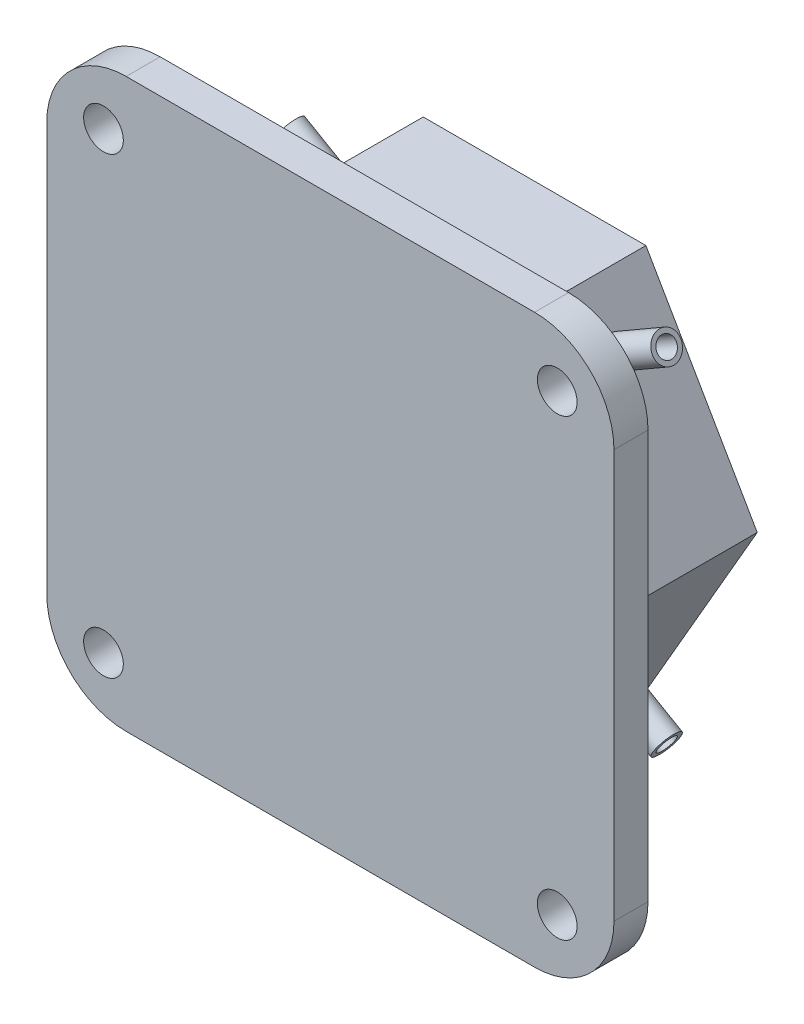
from build123d import *

# Parameters (mm, degrees)
SKETCH_1_R           = 1.75
EXTRUDE_3_DEPTH      = 3
EXTRUDE_4_DEPTH      = 15
SKETCH_3_R           = 1
CUT_EXTRUDE_5_DEPTH  = 7.5
SKETCH_8_R           = 0.85
CUT_EXTRUDE_8_DEPTH  = 9
SKETCH_10_R          = 0.85
CUT_EXTRUDE_9_DEPTH  = 9
SKETCH_11_R          = 0.85
CUT_EXTRUDE_10_DEPTH = 9
SKETCH_12_R          = 0.85
CUT_EXTRUDE_11_DEPTH = 9
SKETCH_13_R          = 1.25
SKETCH_13_R_2        = 0.85
EXTRUDE_5_DEPTH      = 5
SKETCH_14_R          = 1.25
SKETCH_14_R_2        = 0.85
EXTRUDE_6_DEPTH      = 5
SKETCH_15_R          = 1.25
SKETCH_15_R_2        = 0.85
EXTRUDE_7_DEPTH      = 5
SKETCH_16_R          = 1.25
SKETCH_16_R_2        = 0.85
EXTRUDE_8_DEPTH      = 5
SKETCH_17_R          = 1.25
SKETCH_17_R_2        = 1
EXTRUDE_9_DEPTH      = 5


with BuildPart() as part:
    # 草图1 → 凸台-拉伸3 (new body)
    with BuildSketch(Plane.XY):
        with BuildLine():
            Line((-18, -25), (18, -25))
            ThreePointArc((18, -25), (22.949747468, -22.949747468), (25, -18))
            Line((25, -18), (25, 18))
            ThreePointArc((25, 18), (22.949747468, 22.949747468), (18, 25))
            Line((18, 25), (-18, 25))
            ThreePointArc((-18, 25), (-22.949747468, 22.949747468), (-25, 18))
            Line((-25, 18), (-25, -18))
            ThreePointArc((-25, -18), (-22.949747468, -22.949747468), (-18, -25))
        make_face()
        with Locations((20, 20)):
            Circle(SKETCH_1_R, mode=Mode.SUBTRACT)
        with Locations((-20, 20)):
            Circle(SKETCH_1_R, mode=Mode.SUBTRACT)
        with Locations((-20, -20)):
            Circle(SKETCH_1_R, mode=Mode.SUBTRACT)
        with Locations((20, -20)):
            Circle(SKETCH_1_R, mode=Mode.SUBTRACT)
    extrude(amount=EXTRUDE_3_DEPTH)

    # 草图2 → 凸台-拉伸4 (add)
    with BuildSketch(Plane(origin=(0, 0, 0), x_dir=(-1, 0, 0), z_dir=(0, 0, -1))):
        Polygon((9.814954576, -17), (19.629909152, 0), (9.814954576, 17), (-9.814954576, 17), (-19.629909152, 0), (-9.814954576, -17), align=None)
    extrude(amount=EXTRUDE_4_DEPTH)

    # 草图3 → 切除-拉伸5 (cut)
    with BuildSketch(Plane(origin=(0, 0, -15), x_dir=(-1, 0, 0), z_dir=(0, 0, -1))):
        with Locations((-4.815101245, 8.34)):
            Circle(SKETCH_3_R)
        with Locations((4.815101245, 8.34)):
            Circle(SKETCH_3_R)
        with Locations((4.815101245, -8.34)):
            Circle(SKETCH_3_R)
        with Locations((-4.815101245, -8.34)):
            Circle(SKETCH_3_R)
    extrude(amount=-CUT_EXTRUDE_5_DEPTH, mode=Mode.SUBTRACT)

    # 草图8 → 切除-拉伸8 (cut)
    with BuildSketch(Plane(origin=(14.722431864, 8.5, 0), x_dir=(0, 0, -1), z_dir=(0.866025404, 0.5, 0))):
        with Locations((10, 4.814954576)):
            Circle(SKETCH_8_R)
    extrude(amount=-CUT_EXTRUDE_8_DEPTH, mode=Mode.SUBTRACT)

    # 草图10 → 切除-拉伸9 (cut)
    with BuildSketch(Plane(origin=(-14.722431864, 8.5, 0), x_dir=(0, 0, 1), z_dir=(-0.866025404, 0.5, 0))):
        with Locations((-10, 4.814954576)):
            Circle(SKETCH_10_R)
    extrude(amount=-CUT_EXTRUDE_9_DEPTH, mode=Mode.SUBTRACT)

    # 草图11 → 切除-拉伸10 (cut)
    with BuildSketch(Plane(origin=(-14.722431864, -8.5, 0), x_dir=(0, 0, 1), z_dir=(-0.866025404, -0.5, 0))):
        with Locations((-10, -4.814954576)):
            Circle(SKETCH_11_R)
    extrude(amount=-CUT_EXTRUDE_10_DEPTH, mode=Mode.SUBTRACT)

    # 草图12 → 切除-拉伸11 (cut)
    with BuildSketch(Plane(origin=(14.722431864, -8.5, 0), x_dir=(0, 0, -1), z_dir=(0.866025404, -0.5, 0))):
        with Locations((10, -4.814954576)):
            Circle(SKETCH_12_R)
    extrude(amount=-CUT_EXTRUDE_11_DEPTH, mode=Mode.SUBTRACT)

    # 草图13 → 凸台-拉伸5 (add)
    with BuildSketch(Plane(origin=(14.722431864, 8.5, 0), x_dir=(0, 0, -1), z_dir=(0.866025404, 0.5, 0))):
        with Locations((10, 4.814954576)):
            Circle(SKETCH_13_R)
        with Locations((10, 4.814954576)):
            Circle(SKETCH_13_R_2, mode=Mode.SUBTRACT)
    extrude(amount=EXTRUDE_5_DEPTH)

    # 草图14 → 凸台-拉伸6 (add)
    with BuildSketch(Plane(origin=(-14.722431864, 8.5, 0), x_dir=(0, 0, 1), z_dir=(-0.866025404, 0.5, 0))):
        with Locations((-10, 4.814954576)):
            Circle(SKETCH_14_R)
        with Locations((-10, 4.814954576)):
            Circle(SKETCH_14_R_2, mode=Mode.SUBTRACT)
    extrude(amount=EXTRUDE_6_DEPTH)

    # 草图15 → 凸台-拉伸7 (add)
    with BuildSketch(Plane(origin=(-14.722431864, -8.5, 0), x_dir=(0, 0, 1), z_dir=(-0.866025404, -0.5, 0))):
        with Locations((-10, -4.814954576)):
            Circle(SKETCH_15_R)
        with Locations((-10, -4.814954576)):
            Circle(SKETCH_15_R_2, mode=Mode.SUBTRACT)
    extrude(amount=EXTRUDE_7_DEPTH)

    # 草图16 → 凸台-拉伸8 (add)
    with BuildSketch(Plane(origin=(14.722431864, -8.5, 0), x_dir=(0, 0, -1), z_dir=(0.866025404, -0.5, 0))):
        with Locations((10, -4.814954576)):
            Circle(SKETCH_16_R)
        with Locations((10, -4.814954576)):
            Circle(SKETCH_16_R_2, mode=Mode.SUBTRACT)
    extrude(amount=EXTRUDE_8_DEPTH)

    # 草图17 → 凸台-拉伸9 (add)
    with BuildSketch(Plane(origin=(0, 0, -15), x_dir=(-1, 0, 0), z_dir=(0, 0, -1))):
        with Locations((4.815101245, 8.34)):
            Circle(SKETCH_17_R)
        with Locations((4.815101245, 8.34)):
            Circle(SKETCH_17_R_2, mode=Mode.SUBTRACT)
        with Locations((-4.815101245, 8.34)):
            Circle(SKETCH_17_R)
        with Locations((-4.815101245, 8.34)):
            Circle(SKETCH_17_R_2, mode=Mode.SUBTRACT)
        with Locations((-4.815101245, -8.34)):
            Circle(SKETCH_17_R)
        with Locations((-4.815101245, -8.34)):
            Circle(SKETCH_17_R_2, mode=Mode.SUBTRACT)
        with Locations((4.815101245, -8.34)):
            Circle(SKETCH_17_R)
        with Locations((4.815101245, -8.34)):
            Circle(SKETCH_17_R_2, mode=Mode.SUBTRACT)
    extrude(amount=EXTRUDE_9_DEPTH)


solid = part.part
